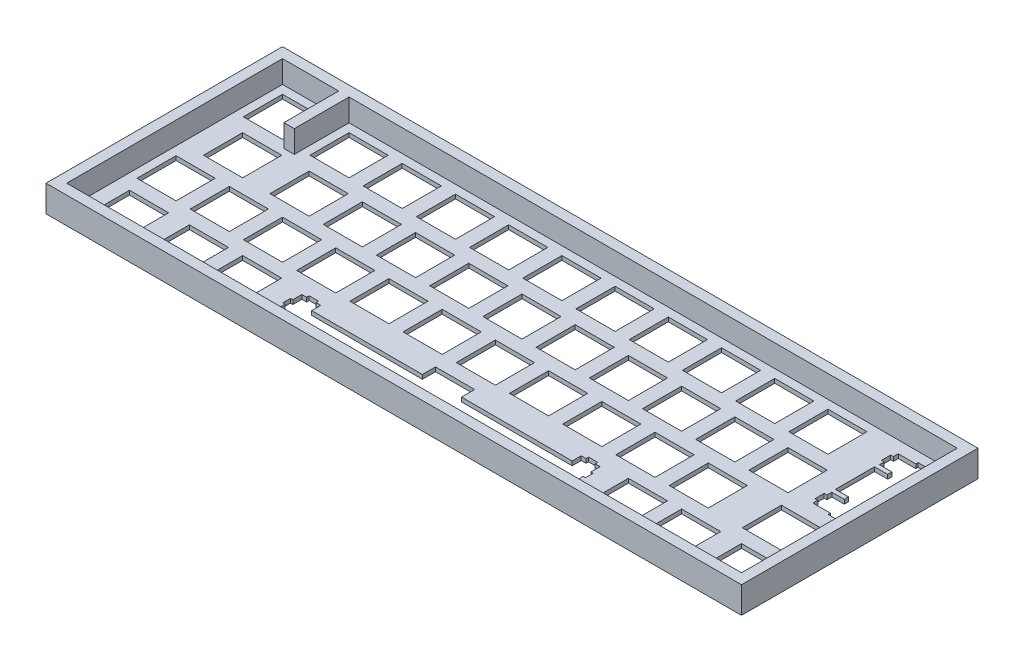
from build123d import *

# Parameters (mm, degrees)
ESQUISSE2_W        = 248.97535
ESQUISSE2_H        = 84.66946
ESQUISSE2_W_2      = 13.999
ESQUISSE2_H_2      = 13.99946
ESQUISSE2_W_3      = 13.9993
ESQUISSE2_W_4      = 13.99949
ESQUISSE2_W_5      = 14.001
ESQUISSE2_H_3      = 13.9994
ESQUISSE2_W_6      = 14.0007
ESQUISSE2_W_7      = 13.99955
ESQUISSE2_H_4      = 13.9993
ESQUISSE2_W_8      = 13.99954
ESQUISSE2_W_9      = 14
BOSS_EXTRU_1_DEPTH = 1.5
ESQUISSE4_W        = 248.97535
ESQUISSE4_H        = 84.66946
BOSS_EXTRU_2_DEPTH = 8


with BuildPart() as part:
    # Esquisse2 → Boss.-Extru.1 (new body)
    with BuildSketch(Plane(origin=(0, 0, 0), x_dir=(1, 0, 0), z_dir=(0, 1, 0))):
        with Locations((120.347325, 38.35837)):
            Rectangle(ESQUISSE2_W, ESQUISSE2_H)
        Polygon((114.537, 16.7831), (114.537, 12.0826), (74.9131, 12.0826), (74.9131, 15.3128), (73.1876, 15.3128), (73.1876, 16.2347), (69.887, 16.2347), (69.887, 15.3128), (68.162, 15.3128), (68.162, 12.0826), (67.3379, 12.0826), (67.3379, 9.28384), (68.162, 9.28384), (68.162, 3.01377), (69.887, 3.01377), (69.887, 2.03261), (73.1876, 2.03261), (73.1876, 3.01377), (74.9131, 3.01377), (74.9131, 7.48273), (114.537, 7.48273), (114.537, 2.78364), (128.538, 2.78364), (128.538, 7.48273), (168.162, 7.48273), (168.162, 3.01377), (169.887, 3.01377), (169.887, 2.03261), (173.188, 2.03261), (173.188, 3.01377), (174.913, 3.01377), (174.913, 9.28384), (175.737, 9.28384), (175.737, 12.0826), (174.913, 12.0826), (174.913, 15.3128), (173.188, 15.3128), (173.188, 16.2347), (169.887, 16.2347), (169.887, 15.3128), (168.162, 15.3128), (168.162, 12.0826), (128.538, 12.0826), (128.538, 16.7831), align=None, mode=Mode.SUBTRACT)
        with Locations((231.0755, 9.78337)):
            Rectangle(ESQUISSE2_W_2, ESQUISSE2_H_2, mode=Mode.SUBTRACT)
        with Locations((209.6445, 9.78337)):
            Rectangle(ESQUISSE2_W_2, ESQUISSE2_H_2, mode=Mode.SUBTRACT)
        with Locations((190.5945, 9.78337)):
            Rectangle(ESQUISSE2_W_2, ESQUISSE2_H_2, mode=Mode.SUBTRACT)
        with Locations((52.48185, 9.78337)):
            Rectangle(ESQUISSE2_W_3, ESQUISSE2_H_2, mode=Mode.SUBTRACT)
        with Locations((33.43185, 9.78337)):
            Rectangle(ESQUISSE2_W_3, ESQUISSE2_H_2, mode=Mode.SUBTRACT)
        with Locations((12.000655, 9.78337)):
            Rectangle(ESQUISSE2_W_4, ESQUISSE2_H_2, mode=Mode.SUBTRACT)
        with Locations((226.3125, 28.8333)):
            Rectangle(ESQUISSE2_W_5, ESQUISSE2_H_3, mode=Mode.SUBTRACT)
        with Locations((200.1195, 28.8333)):
            Rectangle(ESQUISSE2_W_2, ESQUISSE2_H_3, mode=Mode.SUBTRACT)
        with Locations((181.0695, 28.8333)):
            Rectangle(ESQUISSE2_W_2, ESQUISSE2_H_3, mode=Mode.SUBTRACT)
        with Locations((162.0195, 28.8333)):
            Rectangle(ESQUISSE2_W_2, ESQUISSE2_H_3, mode=Mode.SUBTRACT)
        with Locations((142.9695, 28.8333)):
            Rectangle(ESQUISSE2_W_2, ESQUISSE2_H_3, mode=Mode.SUBTRACT)
        with Locations((123.9185, 28.8333)):
            Rectangle(ESQUISSE2_W_5, ESQUISSE2_H_3, mode=Mode.SUBTRACT)
        with Locations((104.86865, 28.8333)):
            Rectangle(ESQUISSE2_W_6, ESQUISSE2_H_3, mode=Mode.SUBTRACT)
        with Locations((85.81935, 28.8333)):
            Rectangle(ESQUISSE2_W_3, ESQUISSE2_H_3, mode=Mode.SUBTRACT)
        with Locations((66.76935, 28.8333)):
            Rectangle(ESQUISSE2_W_3, ESQUISSE2_H_3, mode=Mode.SUBTRACT)
        with Locations((47.71935, 28.8333)):
            Rectangle(ESQUISSE2_W_3, ESQUISSE2_H_3, mode=Mode.SUBTRACT)
        with Locations((28.66935, 28.8333)):
            Rectangle(ESQUISSE2_W_3, ESQUISSE2_H_3, mode=Mode.SUBTRACT)
        with Locations((9.619425, 28.8333)):
            Rectangle(ESQUISSE2_W_7, ESQUISSE2_H_3, mode=Mode.SUBTRACT)
        with Locations((209.6445, 47.88345)):
            Rectangle(ESQUISSE2_W_2, ESQUISSE2_H_4, mode=Mode.SUBTRACT)
        with Locations((190.5945, 47.88345)):
            Rectangle(ESQUISSE2_W_2, ESQUISSE2_H_4, mode=Mode.SUBTRACT)
        with Locations((171.5445, 47.88345)):
            Rectangle(ESQUISSE2_W_2, ESQUISSE2_H_4, mode=Mode.SUBTRACT)
        with Locations((152.4945, 47.88345)):
            Rectangle(ESQUISSE2_W_2, ESQUISSE2_H_4, mode=Mode.SUBTRACT)
        with Locations((133.4445, 47.88345)):
            Rectangle(ESQUISSE2_W_2, ESQUISSE2_H_4, mode=Mode.SUBTRACT)
        with Locations((114.3945, 47.88345)):
            Rectangle(ESQUISSE2_W_2, ESQUISSE2_H_4, mode=Mode.SUBTRACT)
        with Locations((95.34435, 47.88345)):
            Rectangle(ESQUISSE2_W_3, ESQUISSE2_H_4, mode=Mode.SUBTRACT)
        with Locations((76.29435, 47.88345)):
            Rectangle(ESQUISSE2_W_3, ESQUISSE2_H_4, mode=Mode.SUBTRACT)
        with Locations((57.24435, 47.88345)):
            Rectangle(ESQUISSE2_W_3, ESQUISSE2_H_4, mode=Mode.SUBTRACT)
        with Locations((38.19435, 47.88345)):
            Rectangle(ESQUISSE2_W_3, ESQUISSE2_H_4, mode=Mode.SUBTRACT)
        with Locations((14.38193, 47.88345)):
            Rectangle(ESQUISSE2_W_8, ESQUISSE2_H_4, mode=Mode.SUBTRACT)
        Polygon((230.576, 73.5087), (230.576, 72.6832), (224.306, 72.6832), (224.306, 70.9581), (223.325, 70.9581), (223.325, 67.6589), (224.306, 67.6589), (224.306, 65.9335), (228.775, 65.9335), (228.775, 64.4081), (224.076, 64.4081), (224.076, 50.4088), (228.775, 50.4088), (228.775, 48.883), (224.306, 48.883), (224.306, 47.1579), (223.325, 47.1579), (223.325, 43.8587), (224.306, 43.8587), (224.306, 42.1337), (230.576, 42.1337), (230.576, 41.3082), (233.375, 41.3082), (233.375, 42.1337), (236.605, 42.1337), (236.605, 43.8587), (237.526, 43.8587), (237.526, 47.1579), (236.605, 47.1579), (236.605, 48.883), (233.375, 48.883), (233.375, 50.4088), (238.075, 50.4088), (238.075, 64.4081), (233.375, 64.4081), (233.375, 65.9335), (236.605, 65.9335), (236.605, 67.6589), (237.526, 67.6589), (237.526, 70.9581), (236.605, 70.9581), (236.605, 72.6832), (233.375, 72.6832), (233.375, 73.5087), align=None, mode=Mode.SUBTRACT)
        with Locations((204.882, 66.93345)):
            Rectangle(ESQUISSE2_W_9, ESQUISSE2_H_4, mode=Mode.SUBTRACT)
        with Locations((185.832, 66.93345)):
            Rectangle(ESQUISSE2_W_9, ESQUISSE2_H_4, mode=Mode.SUBTRACT)
        with Locations((166.782, 66.93345)):
            Rectangle(ESQUISSE2_W_9, ESQUISSE2_H_4, mode=Mode.SUBTRACT)
        with Locations((147.732, 66.93345)):
            Rectangle(ESQUISSE2_W_9, ESQUISSE2_H_4, mode=Mode.SUBTRACT)
        with Locations((128.682, 66.93345)):
            Rectangle(ESQUISSE2_W_9, ESQUISSE2_H_4, mode=Mode.SUBTRACT)
        with Locations((109.632, 66.93345)):
            Rectangle(ESQUISSE2_W_9, ESQUISSE2_H_4, mode=Mode.SUBTRACT)
        with Locations((90.58185, 66.93345)):
            Rectangle(ESQUISSE2_W_3, ESQUISSE2_H_4, mode=Mode.SUBTRACT)
        with Locations((71.53185, 66.93345)):
            Rectangle(ESQUISSE2_W_3, ESQUISSE2_H_4, mode=Mode.SUBTRACT)
        with Locations((52.48185, 66.93345)):
            Rectangle(ESQUISSE2_W_3, ESQUISSE2_H_4, mode=Mode.SUBTRACT)
        with Locations((33.43185, 66.93345)):
            Rectangle(ESQUISSE2_W_3, ESQUISSE2_H_4, mode=Mode.SUBTRACT)
        with Locations((9.619425, 66.93345)):
            Rectangle(ESQUISSE2_W_7, ESQUISSE2_H_4, mode=Mode.SUBTRACT)
    extrude(amount=BOSS_EXTRU_1_DEPTH)

    # Esquisse4 → Boss.-Extru.2 (add)
    with BuildSketch(Plane(origin=(0, 1.5, 0), x_dir=(1, 0, 0), z_dir=(0, 1, 0))):
        with Locations((120.347325, 38.35837)):
            Rectangle(ESQUISSE4_W, ESQUISSE4_H)
        Polygon((-0.43035, 76.9831), (19.6692, 76.9831), (19.6692, 57.3831), (23.3822, 57.3831), (23.3822, 76.9831), (241.125, 76.9831), (241.125, -0.26636), (-0.43035, -0.26636), align=None, mode=Mode.SUBTRACT)
    extrude(amount=BOSS_EXTRU_2_DEPTH)


solid = part.part
